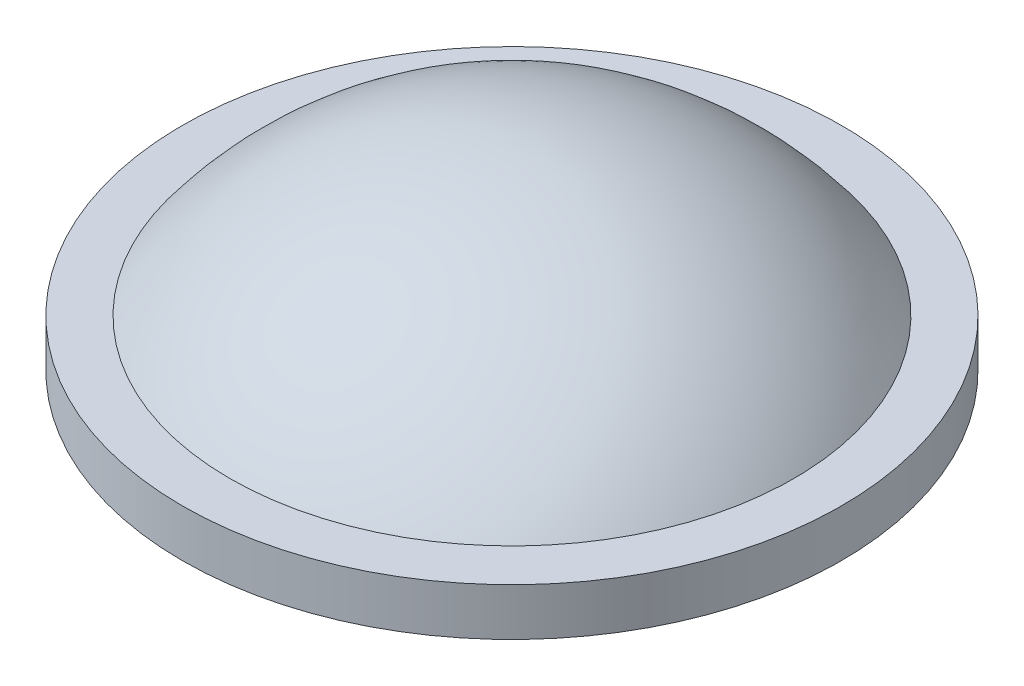
from build123d import *


with BuildPart() as part:
    # Sketch1 → Revolve1 (revolve)
    with BuildSketch(Plane(origin=(0, 0, 0), x_dir=(0, 0, -1), z_dir=(1, 0, 0))):
        with BuildLine():
            Line((0, 0), (-6.25, 0))
            Line((-6.25, 0), (-6.25, 0.9))
            Line((-6.25, 0.9), (-5.35, 0.9))
            ThreePointArc((-5.35, 0.9), (-2.996351949, 2.886752935), (0, 3.6))
            Line((0, 3.6), (0, 0))
        make_face()
    revolve(axis=Axis((0, 3.6, 0), (0, -1, 0)))


solid = part.part
